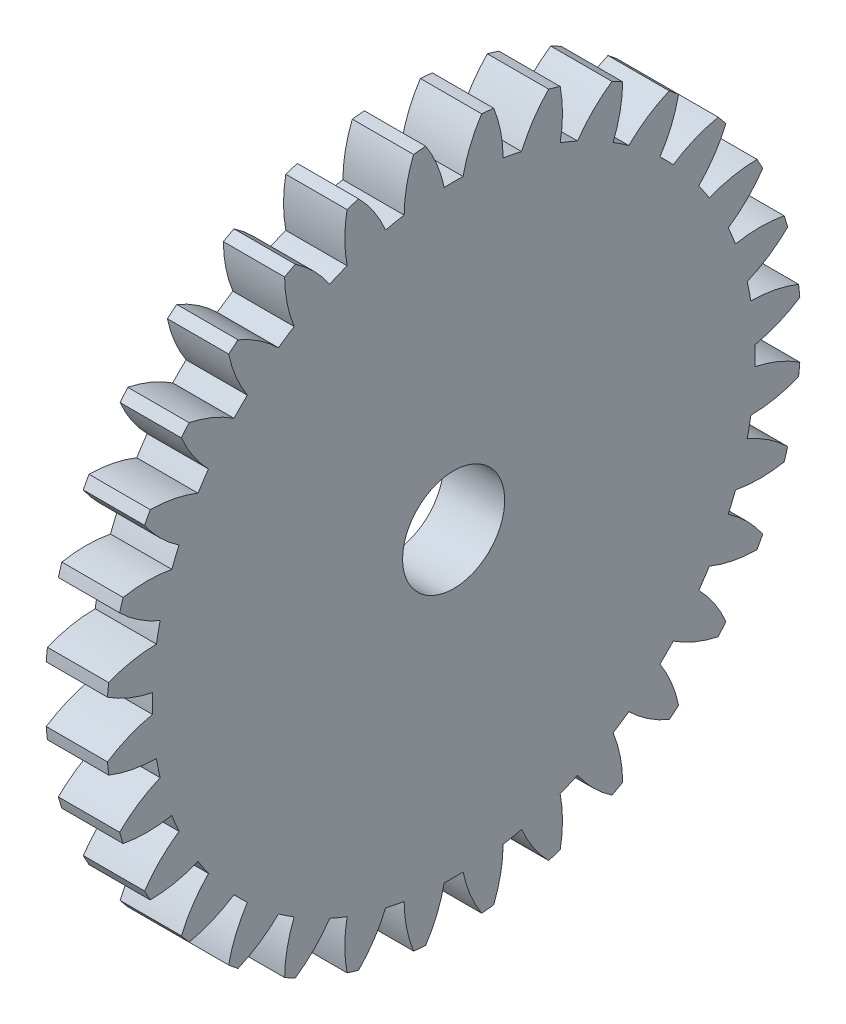
from build123d import *

# Parameters (mm, degrees)
BASPROSKE_W     = 3
BASPROSKE_H     = 17
TOOTHCUT_DEPTH  = 25.228082879
TEETHCUTS_COUNT = 32
TEETHCUTS_ANGLE = 348.75
BORSKE_R        = 2.5
BORE_DEPTH      = 50.0000508


with BuildPart() as part:
    # BasProSke → Base-Revolve (revolve)
    with BuildSketch(Plane(origin=(0, 0, 0), x_dir=(1, 0, 0), z_dir=(0, 1, 0)), mode=Mode.PRIVATE) as base_revolve_sk:
        with Locations((1.5, 8.5)):
            Rectangle(BASPROSKE_W, BASPROSKE_H)
    revolve(base_revolve_sk.sketch.rotate(Axis((-10, 0, 0), (1, 0, 0)), 180), axis=Axis((-10, 0, 0), (1, 0, 0)))

    # TooCutSke → ToothCut (cut, through all)
    with BuildSketch(Plane(origin=(0, 0, 0), x_dir=(0, 0, -1), z_dir=(1, 0, 0))):
        with BuildLine():
            ThreePointArc((0.462036907, 14.741761187), (0, 14.749), (-0.462036907, 14.741761187))
            ThreePointArc((-0.462036907, 14.741761187), (-0.81854142, 15.899240468), (-1.386721275, 16.9688317))
            ThreePointArc((-1.386721275, 16.9688317), (0, 17.0254), (1.386721275, 16.9688317))
            ThreePointArc((1.386721275, 16.9688317), (0.81854142, 15.899240468), (0.462036907, 14.741761187))
        make_face()
    toothcut = extrude(amount=TOOTHCUT_DEPTH, mode=Mode.SUBTRACT)

    # TeethCuts: ToothCut ×32 about axis
    teethcuts_axis = Axis((-10, 0, 0), (1, 0, 0))
    for i in range(1, TEETHCUTS_COUNT):
        add(toothcut.rotate(teethcuts_axis, i * TEETHCUTS_ANGLE / (TEETHCUTS_COUNT - 1)), mode=Mode.SUBTRACT)

    # BorSke → Bore (cut, symmetric)
    with BuildSketch(Plane(origin=(0, 0, 0), x_dir=(0, 0, -1), z_dir=(1, 0, 0))):
        with Locations(Location((0, 0, 0), (0, 0, 180))):
            Circle(BORSKE_R)
    extrude(amount=BORE_DEPTH, both=True, mode=Mode.SUBTRACT)


solid = part.part
